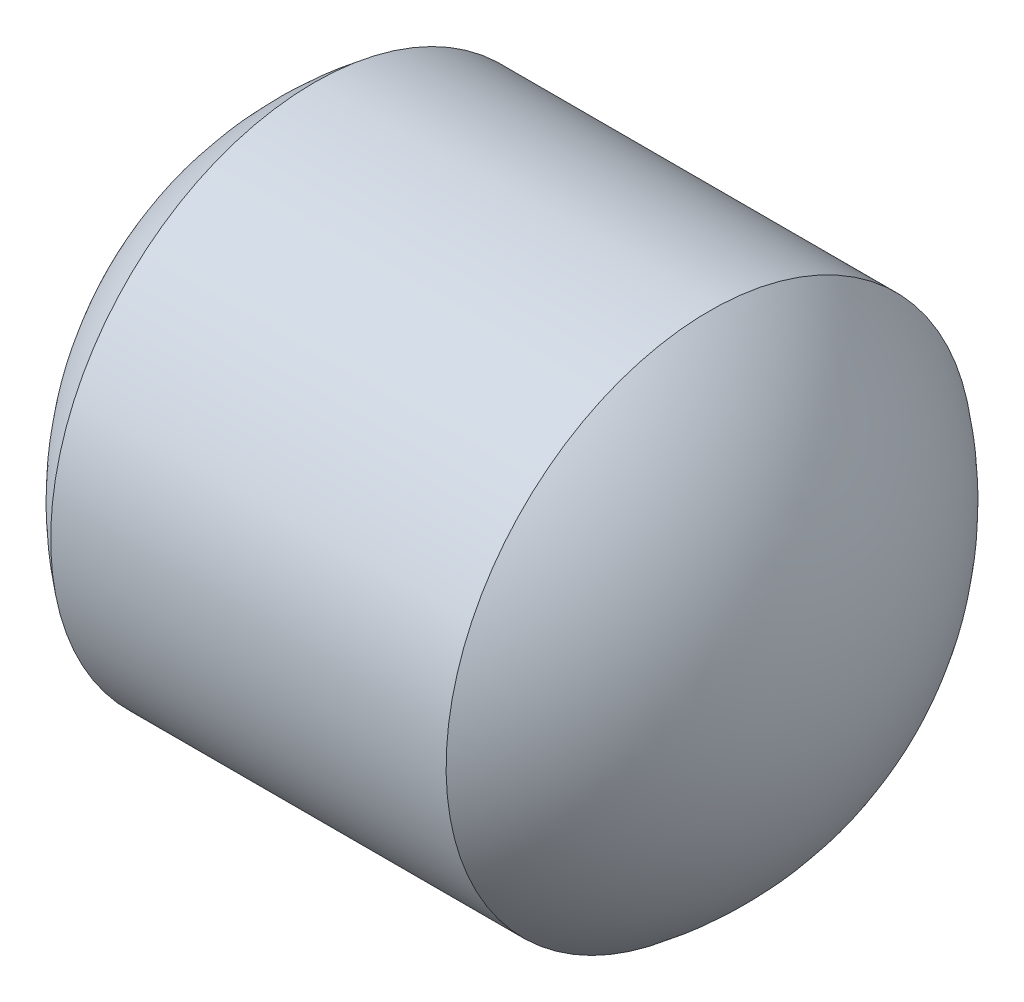
from build123d import *


with BuildPart() as part:
    # 草图1 one side → 旋转1 (revolve)
    with BuildSketch(Plane.XY, mode=Mode.PRIVATE) as revolve_1_sk:
        with BuildLine():
            Line((0.75, 1), (-0.75, 1))
            ThreePointArc((-0.75, 1), (-1.118033989, 0.559016994), (-1.25, 0))
            Line((-1.25, 0), (1.25, 0))
            ThreePointArc((1.25, 0), (1.118033989, 0.559016994), (0.75, 1))
        make_face()
    revolve(revolve_1_sk.sketch.rotate(Axis((-1.619607495, 0, 0), (1, 0, 0)), 180), axis=Axis((-1.619607495, 0, 0), (1, 0, 0)))  # turned: the seam where the file's is


solid = part.part
